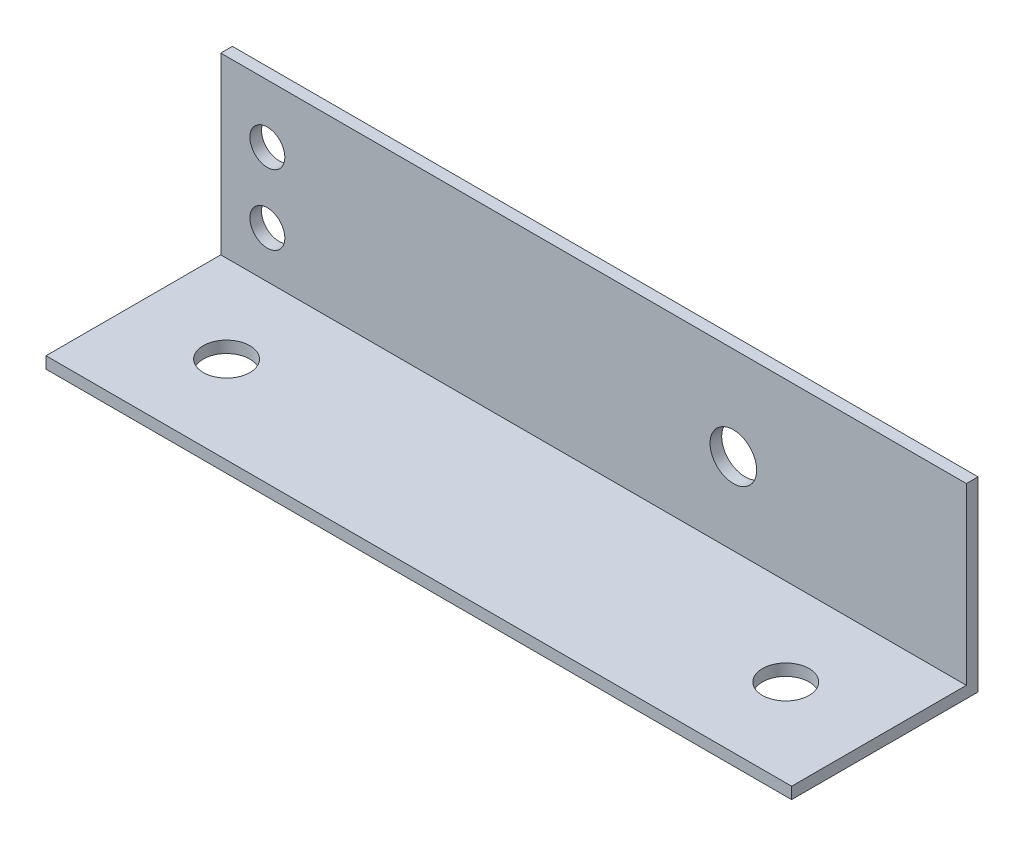
from build123d import *

# Parameters (mm, degrees)
BOSS_EXTRUDE1_DEPTH = 101.6
SKETCH2_R           = 3.175
CUT_EXTRUDE1_DEPTH  = 101.6
SKETCH3_R           = 3.175
SKETCH3_R_2         = 2.38125
CUT_EXTRUDE2_DEPTH  = 101.6


with BuildPart() as part:
    # Sketch1 → Boss-Extrude1 (new body)
    with BuildSketch(Plane(origin=(0, 0, 0), x_dir=(0, 0, -1), z_dir=(1, 0, 0))):
        Polygon((0, 0), (0, 25.4), (-1.5875, 25.4), (-1.5875, 1.5875), (-25.4, 1.5875), (-25.4, 0), align=None)
    extrude(amount=BOSS_EXTRUDE1_DEPTH)

    # Sketch2 → Cut-Extrude1 (cut)
    with BuildSketch(Plane(origin=(0, 1.5875, 0), x_dir=(1, 0, 0), z_dir=(0, 1, 0))):
        with Locations((12.7, -13.49375)):
            Circle(SKETCH2_R)
        with Locations((88.9, -13.49375)):
            Circle(SKETCH2_R)
    extrude(amount=-CUT_EXTRUDE1_DEPTH, mode=Mode.SUBTRACT)

    # Sketch3 → Cut-Extrude2 (cut)
    with BuildSketch(Plane.XY.offset(1.5875)):
        with Locations((69.85, 12.7)):
            Circle(SKETCH3_R)
        with Locations((6.35, 17.4625)):
            Circle(SKETCH3_R_2)
        with Locations((6.35, 7.9375)):
            Circle(SKETCH3_R_2)
    extrude(amount=-CUT_EXTRUDE2_DEPTH, mode=Mode.SUBTRACT)


solid = part.part
